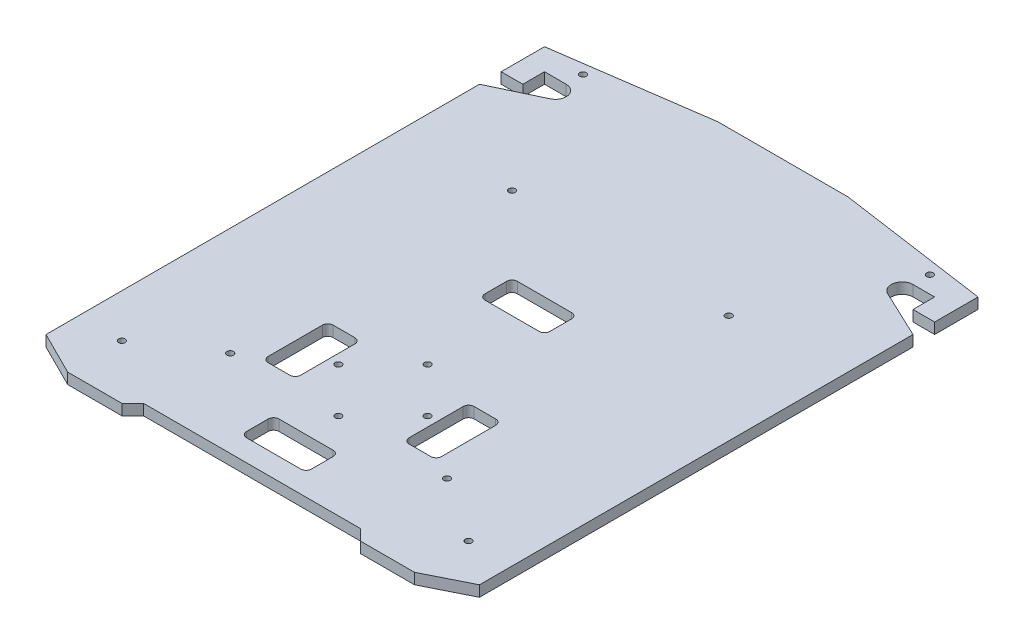
from build123d import *

# Parameters (mm, degrees)
SKETCH_1_W           = 200
SKETCH_1_H           = 250
EXTRUDE_1_DEPTH      = 5
CUT_EXTRUDE_1_DEPTH  = 35
CUT_EXTRUDE_2_DEPTH  = 35
CUT_EXTRUDE_3_DEPTH  = 35
CUT_EXTRUDE_5_DEPTH  = 30
CUT_EXTRUDE_6_DEPTH  = 10
CUT_EXTRUDE_7_DEPTH  = 10
SKETCH_9_R           = 1.5
CUT_EXTRUDE_8_DEPTH  = 10
SKETCH_10_R          = 1.5
CUT_EXTRUDE_9_DEPTH  = 10
SKETCH_12_R          = 1.5
CUT_EXTRUDE_10_DEPTH = 10
SKETCH_13_R          = 1.5
CUT_EXTRUDE_11_DEPTH = 10


with BuildPart() as part:
    # 草图1 → 凸台-拉伸1 (new body)
    with BuildSketch(Plane(origin=(0, 0, 0), x_dir=(1, 0, 0), z_dir=(0, 1, 0))):
        Rectangle(SKETCH_1_W, SKETCH_1_H)
    extrude(amount=EXTRUDE_1_DEPTH)

    # 草图2 → 切除-拉伸1 (cut)
    with BuildSketch(Plane(origin=(0, 5, 0), x_dir=(1, 0, 0), z_dir=(0, 1, 0))):
        Polygon((-100, -115), (-80, -125), (-100, -125), align=None)
    cut_extrude_1 = extrude(amount=-CUT_EXTRUDE_1_DEPTH, mode=Mode.SUBTRACT)

    # 镜向1: 切除-拉伸1 across plane
    add(cut_extrude_1.mirror(Plane(origin=(0, 0, 0), x_dir=(0, 0, 1), z_dir=(1, 0, 0))), mode=Mode.SUBTRACT)

    # 草图3 → 切除-拉伸2 (cut)
    with BuildSketch(Plane(origin=(0, 5, 0), x_dir=(1, 0, 0), z_dir=(0, 1, 0))):
        Polygon((-55, -125), (-50, -120), (0, -120), (0, -125), align=None)
    cut_extrude_2 = extrude(amount=-CUT_EXTRUDE_2_DEPTH, mode=Mode.SUBTRACT)

    # 镜向2: 切除-拉伸2 across plane
    add(cut_extrude_2.mirror(Plane(origin=(0, 0, 0), x_dir=(0, 0, 1), z_dir=(1, 0, 0))), mode=Mode.SUBTRACT)

    # 草图4 → 切除-拉伸3 (cut)
    with BuildSketch(Plane(origin=(0, 5, 0), x_dir=(1, 0, 0), z_dir=(0, 1, 0))):
        with BuildLine():
            Line((-12.5, -95), (12.5, -95))
            ThreePointArc((12.5, -95), (14.267766953, -95.732233047), (15, -97.5))
            Line((15, -97.5), (15, -107.5))
            ThreePointArc((15, -107.5), (14.267766953, -109.267766953), (12.5, -110))
            Line((12.5, -110), (-12.5, -110))
            ThreePointArc((-12.5, -110), (-14.267766953, -109.267766953), (-15, -107.5))
            Line((-15, -107.5), (-15, -97.5))
            ThreePointArc((-15, -97.5), (-14.267766953, -95.732233047), (-12.5, -95))
        make_face()
    extrude(amount=-CUT_EXTRUDE_3_DEPTH, mode=Mode.SUBTRACT)

    # 草图5 → 切除-拉伸5 (cut)
    with BuildSketch(Plane(origin=(0, 0, 0), x_dir=(1, 0, 0), z_dir=(0, 1, 0))):
        Polygon((-30, 125), (-100, 115), (-100, 125), align=None)
    cut_extrude_5 = extrude(amount=CUT_EXTRUDE_5_DEPTH, mode=Mode.SUBTRACT)

    # 镜向3: 切除-拉伸5 across plane
    add(cut_extrude_5.mirror(Plane(origin=(0, 0, 0), x_dir=(0, 0, 1), z_dir=(1, 0, 0))), mode=Mode.SUBTRACT)

    # 草图6 → 切除-拉伸6 (cut)
    with BuildSketch(Plane(origin=(0, 5, 0), x_dir=(1, 0, 0), z_dir=(0, 1, 0))):
        with BuildLine():
            Line((-100, 95), (-90, 95))
            Line((-90, 95), (-90, 105))
            Line((-90, 105), (-80, 105))
            ThreePointArc((-80, 105), (-75.121684822, 101.096376317), (-77.860612309, 95.480816412))
            Line((-77.860612309, 95.480816412), (-100, 85))
            Line((-100, 85), (-100, 95))
        make_face()
    cut_extrude_6 = extrude(amount=-CUT_EXTRUDE_6_DEPTH, mode=Mode.SUBTRACT)

    # 镜向4: 切除-拉伸6 across plane
    add(cut_extrude_6.mirror(Plane(origin=(0, 0, 0), x_dir=(0, 0, 1), z_dir=(1, 0, 0))), mode=Mode.SUBTRACT)

    # 草图8 → 切除-拉伸7 (cut)
    with BuildSketch(Plane(origin=(0, 5, 0), x_dir=(1, 0, 0), z_dir=(0, 1, 0))):
        with BuildLine():
            Line((-37.5, -45), (-27.5, -45))
            ThreePointArc((-27.5, -45), (-25.732233047, -45.732233047), (-25, -47.5))
            Line((-25, -47.5), (-25, -72.5))
            ThreePointArc((-25, -72.5), (-25.732233047, -74.267766953), (-27.5, -75))
            Line((-27.5, -75), (-37.5, -75))
            ThreePointArc((-37.5, -75), (-39.267766953, -74.267766953), (-40, -72.5))
            Line((-40, -72.5), (-40, -47.5))
            ThreePointArc((-40, -47.5), (-39.267766953, -45.732233047), (-37.5, -45))
        make_face()
        with BuildLine():
            Line((25, -47.5), (25, -72.5))
            ThreePointArc((25, -72.5), (25.732233047, -74.267766953), (27.5, -75))
            Line((27.5, -75), (37.5, -75))
            ThreePointArc((37.5, -75), (39.267766953, -74.267766953), (40, -72.5))
            Line((40, -72.5), (40, -47.5))
            ThreePointArc((40, -47.5), (39.267766953, -45.732233047), (37.5, -45))
            Line((37.5, -45), (27.5, -45))
            ThreePointArc((27.5, -45), (25.732233047, -45.732233047), (25, -47.5))
        make_face()
        with BuildLine():
            Line((-12.5, 15), (12.5, 15))
            ThreePointArc((12.5, 15), (14.267766953, 14.267766953), (15, 12.5))
            Line((15, 12.5), (15, 2.5))
            ThreePointArc((15, 2.5), (14.267766953, 0.732233047), (12.5, 0))
            Line((12.5, 0), (-12.5, 0))
            ThreePointArc((-12.5, 0), (-14.267766953, 0.732233047), (-15, 2.5))
            Line((-15, 2.5), (-15, 12.5))
            ThreePointArc((-15, 12.5), (-14.267766953, 14.267766953), (-12.5, 15))
        make_face()
    extrude(amount=-CUT_EXTRUDE_7_DEPTH, mode=Mode.SUBTRACT)

    # 草图9 → 切除-拉伸8 (cut)
    with BuildSketch(Plane(origin=(0, 5, 0), x_dir=(1, 0, 0), z_dir=(0, 1, 0))):
        with Locations((-80, -100)):
            Circle(SKETCH_9_R)
        with Locations((80, -100)):
            Circle(SKETCH_9_R)
    extrude(amount=-CUT_EXTRUDE_8_DEPTH, mode=Mode.SUBTRACT)

    # 草图10 → 切除-拉伸9 (cut)
    with BuildSketch(Plane(origin=(0, 5, 0), x_dir=(1, 0, 0), z_dir=(0, 1, 0))):
        with Locations((-80, 112.806380134)):
            Circle(SKETCH_10_R)
        with Locations((80, 112.806380134)):
            Circle(SKETCH_10_R)
    extrude(amount=-CUT_EXTRUDE_9_DEPTH, mode=Mode.SUBTRACT)

    # 草图12 → 切除-拉伸10 (cut)
    with BuildSketch(Plane(origin=(0, 5, 0), x_dir=(1, 0, 0), z_dir=(0, 1, 0))):
        with Locations((0, -38.912086487)):
            Circle(SKETCH_12_R)
        with Locations((-20.60616084, -59.518247327)):
            Circle(SKETCH_12_R)
        with Locations((20.60616084, -59.518247327)):
            Circle(SKETCH_12_R)
        with Locations((0, -80.124408167)):
            Circle(SKETCH_12_R)
    extrude(amount=-CUT_EXTRUDE_10_DEPTH, mode=Mode.SUBTRACT)

    # 草图13 → 切除-拉伸11 (cut)
    with BuildSketch(Plane(origin=(0, 5, 0), x_dir=(1, 0, 0), z_dir=(0, 1, 0))):
        with Locations((-50, -80)):
            Circle(SKETCH_13_R)
        with Locations((50, -80)):
            Circle(SKETCH_13_R)
        with Locations((-50, 50)):
            Circle(SKETCH_13_R)
        with Locations((50, 50)):
            Circle(SKETCH_13_R)
    extrude(amount=-CUT_EXTRUDE_11_DEPTH, mode=Mode.SUBTRACT)


solid = part.part
